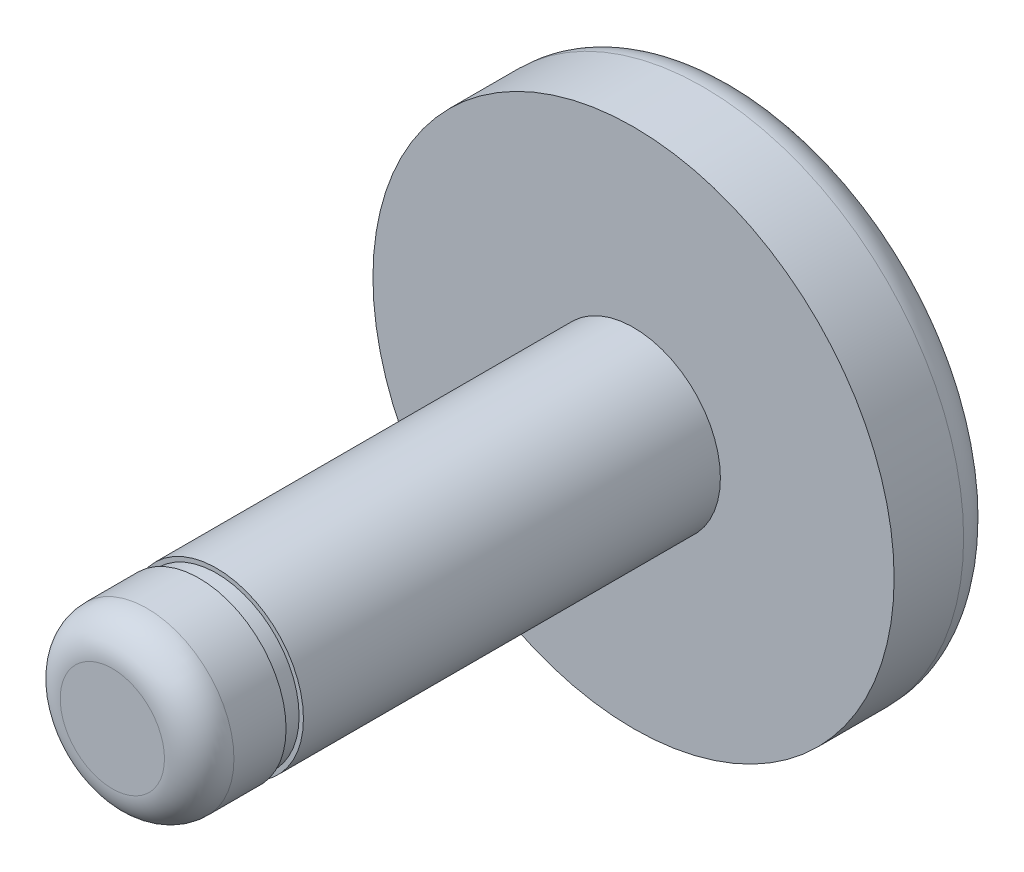
from build123d import *

# Parameters (mm, degrees)
SKETCH1_R               = 7.5
BOSS_EXTRUDE1_DEPTH     = 3
SKETCH3_R               = 2.5
BOSS_EXTRUDE3_DEPTH     = 15
FILLET1_R               = 1
SKETCH4_R               = 12.375
SKETCH4_R_2             = 2.375
CUT_EXTRUDE_THIN1_DEPTH = 0.5


with BuildPart() as part:
    # Sketch1 → Boss-Extrude1 (new body)
    with BuildSketch(Plane.XY):
        Circle(SKETCH1_R)
    extrude(amount=BOSS_EXTRUDE1_DEPTH)

    # Sketch3 → Boss-Extrude3 (add)
    with BuildSketch(Plane.XY.offset(3)):
        Circle(SKETCH3_R)
    extrude(amount=BOSS_EXTRUDE3_DEPTH)

    # Fillet1
    fillet1_edges = [part.edges().sort_by_distance(p)[0] for p in [
        (-7.5, 0, 0),
        (-2.5, 0, 18),
    ]]
    fillet(fillet1_edges, radius=FILLET1_R)

    # Sketch4 → Cut-Extrude-Thin1 (cut)
    with BuildSketch(Plane.XY.offset(15)):
        Circle(SKETCH4_R)
        Circle(SKETCH4_R_2, mode=Mode.SUBTRACT)
    extrude(amount=CUT_EXTRUDE_THIN1_DEPTH, mode=Mode.SUBTRACT)


solid = part.part
